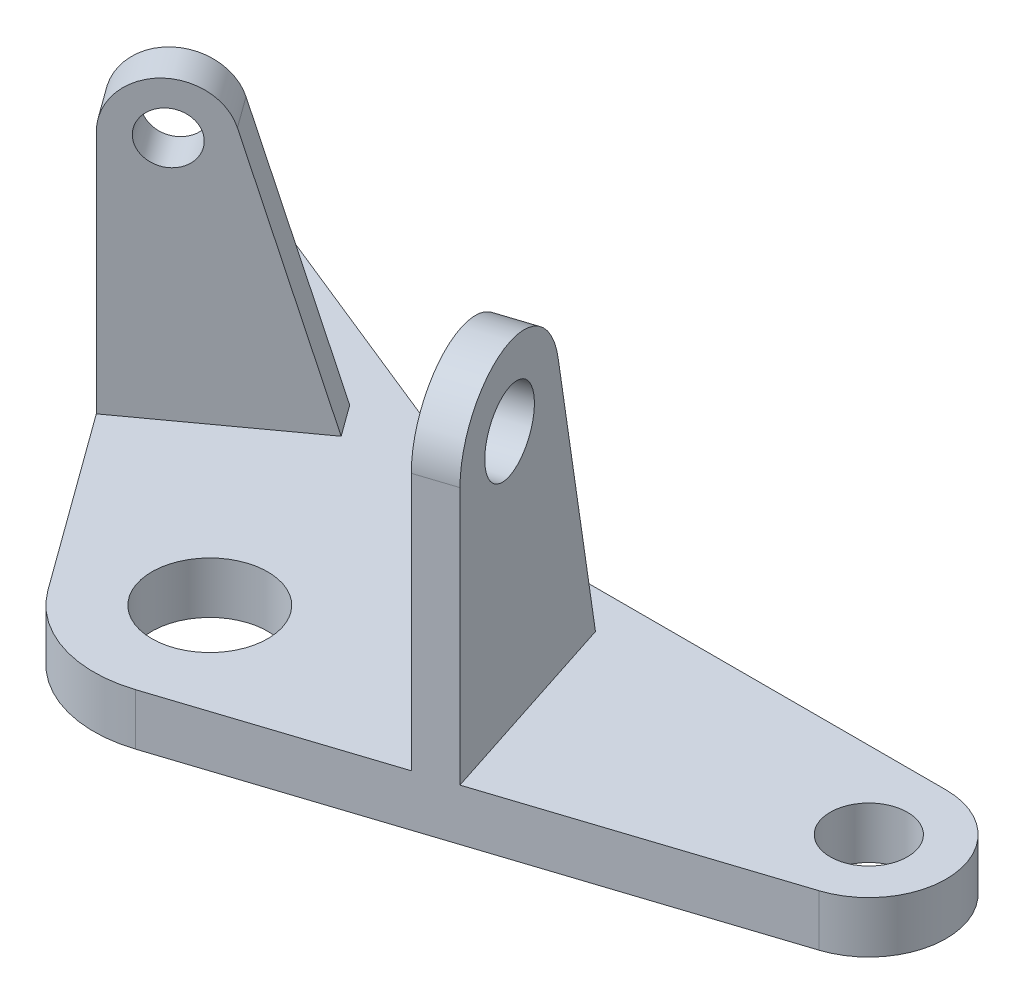
from build123d import *

# Parameters (mm, degrees)
SKETCH1_R           = 9
SKETCH1_R_2         = 6
SKETCH1_R_3         = 4
BOSS_EXTRUDE1_DEPTH = 8
SKETCH3_R           = 8
SKETCH3_R_2         = 4
BOSS_EXTRUDE2_DEPTH = 3
SKETCH5_R           = 12
SKETCH5_R_2         = 6
BOSS_EXTRUDE3_DEPTH = 3
FILLET1_R           = 42


with BuildPart() as part:
    # Sketch1 → Boss-Extrude1 (new body)
    with BuildSketch(Plane(origin=(0, 0, 0), x_dir=(1, 0, 0), z_dir=(0, 1, 0))):
        with BuildLine():
            Line((82, 32.334641746), (14.735908192, 32.334641746))
            Line((14.735908192, 32.334641746), (-45.003147253, 56.470786852))
            ThreePointArc((-45.003147253, 56.470786852), (-54.304086029, 53.978607818), (-54.472135955, 44.351033997))
            Line((-54.472135955, 44.351033997), (-14.562305899, -10.580134541))
            ThreePointArc((-14.562305899, -10.580134541), (-5.562305899, -17.119017293), (5.562305899, -17.119017293))
            Line((5.562305899, -17.119017293), (85.708203932, 8.92196355))
            ThreePointArc((85.708203932, 8.92196355), (93.852260087, 22.211855326), (82, 32.334641746))
        make_face()
        Circle(SKETCH1_R, mode=Mode.SUBTRACT)
        with Locations((82, 20.334641746)):
            Circle(SKETCH1_R_2, mode=Mode.SUBTRACT)
        with Locations((-48, 49.053316016)):
            Circle(SKETCH1_R_3, mode=Mode.SUBTRACT)
    extrude(amount=BOSS_EXTRUDE1_DEPTH)

    # Sketch3 → Boss-Extrude2 (add, symmetric)
    with BuildSketch(Plane(origin=(-21.748054335, 0, -29.933628792), x_dir=(0.809016994, 0, -0.587785252), z_dir=(0.587785252, 0, 0.809016994))):
        with BuildLine():
            Line((-18, 46), (-18, 8))
            Line((-18, 8), (9.218720146, 8))
            Line((9.218720146, 8), (-2.309906432, 48.205098847))
            ThreePointArc((-2.309906432, 48.205098847), (-2.07785545, 47.113384808), (-2, 46))
            ThreePointArc((-2, 46), (-10, 38), (-18, 46))
        make_face()
        with Locations((-10, 46)):
            Circle(SKETCH3_R)
        with Locations((-10, 46)):
            Circle(SKETCH3_R_2, mode=Mode.SUBTRACT)
    extrude(amount=BOSS_EXTRUDE2_DEPTH, both=True)

    # Sketch5 → Boss-Extrude3 (add, symmetric)
    with BuildSketch(Plane(origin=(35.189091103, 0, -11.433628792), x_dir=(-0.309016994, 0, -0.951056516), z_dir=(0.951056516, 0, -0.309016994))):
        with BuildLine():
            Line((-18, 48), (-18, 8))
            Line((-18, 8), (14.770349605, 8))
            Line((14.770349605, 8), (5.737771209, 50.49494029))
            ThreePointArc((5.737771209, 50.49494029), (5.934262744, 49.254341559), (6, 48))
            ThreePointArc((6, 48), (-6, 36), (-18, 48))
        make_face()
        with Locations((-6, 48)):
            Circle(SKETCH5_R)
        with Locations((-6, 48)):
            Circle(SKETCH5_R_2, mode=Mode.SUBTRACT)
    extrude(amount=BOSS_EXTRUDE3_DEPTH, both=True)

    # Fillet1
    fillet1_edges = [part.edges().sort_by_distance(p)[0] for p in [
        (14.735908192, 4, -32.334641746),
    ]]
    fillet(fillet1_edges, radius=FILLET1_R)


solid = part.part
